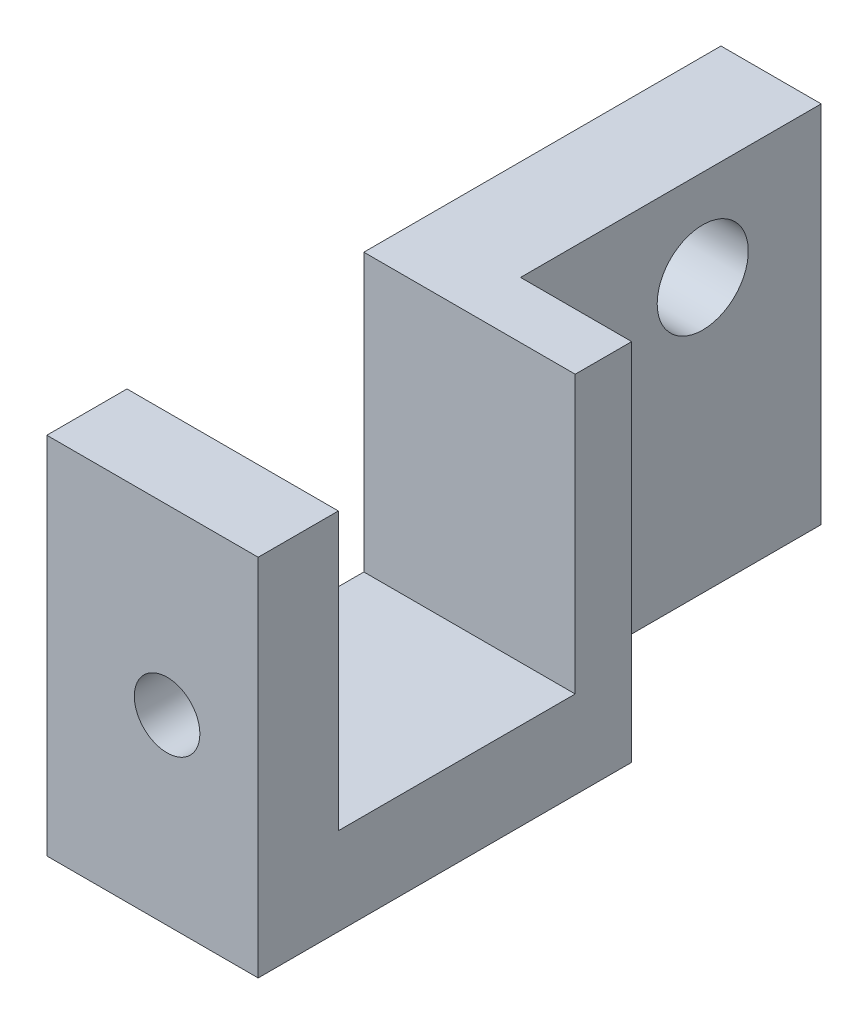
from build123d import *

# Parameters (mm, degrees)
SKETCH1_W           = 14.732
SKETCH1_H           = 46.99
BOSS_EXTRUDE1_DEPTH = 12.7
SKETCH2_W           = 16.51
SKETCH2_H           = 19.304
CUT_EXTRUDE1_DEPTH  = 15.732
CUT_EXTRUDE2_REACH  = 48.99
SKETCH3_R           = 2.286
SKETCH4_W           = 7.747
SKETCH4_H           = 25.4
CUT_EXTRUDE3_DEPTH  = 20.955
SKETCH5_R           = 3.175
CUT_EXTRUDE4_DEPTH  = 15.732


with BuildPart() as part:
    # Sketch1 → Boss-Extrude1 (new body, symmetric)
    with BuildSketch(Plane(origin=(0, 0, 0), x_dir=(1, 0, 0), z_dir=(0, 1, 0))):
        Rectangle(SKETCH1_W, SKETCH1_H)
    extrude(amount=BOSS_EXTRUDE1_DEPTH, both=True)

    # Sketch2 → Cut-Extrude1 (cut, through all)
    with BuildSketch(Plane(origin=(7.366, 0, 0), x_dir=(0, 0, -1), z_dir=(1, 0, 0))):
        with Locations((-9.652, 3.048)):
            Rectangle(SKETCH2_W, SKETCH2_H)
    extrude(amount=-CUT_EXTRUDE1_DEPTH, mode=Mode.SUBTRACT)

    # Sketch3 → Cut-Extrude2 (cut, up to next)
    with BuildSketch(Plane.XY.offset(23.495), mode=Mode.PRIVATE) as cut_extrude2_sk1:
        with Locations((1.016, 0)):
            Circle(SKETCH3_R)
    cut_extrude2_tool1 = extrude(cut_extrude2_sk1.sketch, amount=-CUT_EXTRUDE2_REACH, mode=Mode.PRIVATE) & part.part
    add(cut_extrude2_tool1.solids().sort_by_distance((1.016, 0, 23.495))[0], mode=Mode.SUBTRACT)

    # Sketch4 → Cut-Extrude3 (cut)
    with BuildSketch(Plane(origin=(0, 0, -23.495), x_dir=(-1, 0, 0), z_dir=(0, 0, -1))):
        with Locations((-3.4925, 0)):
            Rectangle(SKETCH4_W, SKETCH4_H)
    extrude(amount=-CUT_EXTRUDE3_DEPTH, mode=Mode.SUBTRACT)

    # Sketch5 → Cut-Extrude4 (cut, through all)
    with BuildSketch(Plane.ZY.offset(7.366)):
        with Locations((-15.24, 6.35)):
            Circle(SKETCH5_R)
    extrude(amount=-CUT_EXTRUDE4_DEPTH, mode=Mode.SUBTRACT)


solid = part.part
